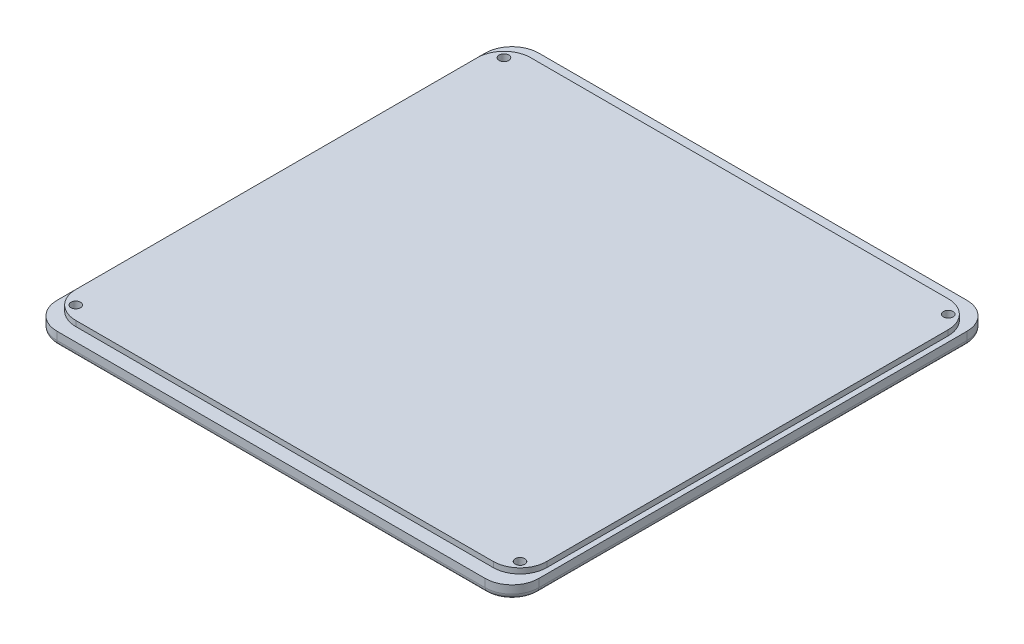
from build123d import *

# Parameters (mm, degrees)
SKIZZE1_W                                            = 180
SKIZZE1_H                                            = 180
AUFSATZ_LINEAR_AUSTRAGEN1_DEPTH                      = 5
AUFSATZ_LINEAR_AUSTRAGEN2_DEPTH                      = 2
STIRNSENKUNG_F_R_M3_ZYLINDERSCHRAUBE_MIT_D           = 3.6
STIRNSENKUNG_F_R_M3_ZYLINDERSCHRAUBE_MIT_DEPTH       = 9.1
STIRNSENKUNG_F_R_M3_ZYLINDERSCHRAUBE_MIT_CBORE_D     = 6.5
STIRNSENKUNG_F_R_M3_ZYLINDERSCHRAUBE_MIT_CBORE_DEPTH = 3.4
STIRNSENKUNG_F_R_M3_ZYLINDERSCHRAUBE_MIT_TIP         = 1.081549114
VERRUNDUNG1_R                                        = 10
VERRUNDUNG2_R                                        = 2


with BuildPart() as part:
    # Skizze1 → Aufsatz-Linear austragen1 (new body)
    with BuildSketch(Plane(origin=(0, 0, 0), x_dir=(1, 0, 0), z_dir=(0, 1, 0))):
        Rectangle(SKIZZE1_W, SKIZZE1_H)
    extrude(amount=AUFSATZ_LINEAR_AUSTRAGEN1_DEPTH)

    # Skizze2 → Aufsatz-Linear austragen2 (add)
    with BuildSketch(Plane(origin=(0, 5, 0), x_dir=(1, 0, 0), z_dir=(0, 1, 0))):
        with BuildLine():
            Line((78, 85), (-78, 85))
            ThreePointArc((-78, 85), (-85.071067812, 82.071067812), (-88, 75))
            Line((-88, 75), (-88, -75))
            ThreePointArc((-88, -75), (-85.071067812, -82.071067812), (-78, -85))
            Line((-78, -85), (78, -85))
            ThreePointArc((78, -85), (85.071067812, -82.071067812), (88, -75))
            Line((88, -75), (88, 75))
            ThreePointArc((88, 75), (85.071067812, 82.071067812), (78, 85))
        make_face()
    extrude(amount=AUFSATZ_LINEAR_AUSTRAGEN2_DEPTH)

    # Stirnsenkung für M3 Zylinderschraube mit Innensechskant2
    with Locations(Plane(origin=(0, 0, 0), x_dir=(-1, 0, 0), z_dir=(0, -1, 0))):
        with Locations((-83, 80), (83, 80), (83, -80), (-83, -80)):
            CounterBoreHole(STIRNSENKUNG_F_R_M3_ZYLINDERSCHRAUBE_MIT_D / 2, STIRNSENKUNG_F_R_M3_ZYLINDERSCHRAUBE_MIT_CBORE_D / 2, STIRNSENKUNG_F_R_M3_ZYLINDERSCHRAUBE_MIT_CBORE_DEPTH, depth=STIRNSENKUNG_F_R_M3_ZYLINDERSCHRAUBE_MIT_DEPTH)
            with Locations((0, 0, -(STIRNSENKUNG_F_R_M3_ZYLINDERSCHRAUBE_MIT_DEPTH + STIRNSENKUNG_F_R_M3_ZYLINDERSCHRAUBE_MIT_TIP / 2))):  # 118° drill point
                Cone(0, STIRNSENKUNG_F_R_M3_ZYLINDERSCHRAUBE_MIT_D / 2, STIRNSENKUNG_F_R_M3_ZYLINDERSCHRAUBE_MIT_TIP, mode=Mode.SUBTRACT)

    # Verrundung1
    verrundung1_edges = [part.edges().sort_by_distance(p)[0] for p in [
        (90, 2.5, -90),
        (90, 2.5, 90),
        (-90, 2.5, 90),
        (-90, 2.5, -90),
    ]]
    fillet(verrundung1_edges, radius=VERRUNDUNG1_R)

    # Verrundung2
    verrundung2_edges = [part.edges().sort_by_distance(p)[0] for p in [
        (90, 0, 0),
        (0, 0, -90),
        (0, 0, 90),
        (-90, 0, 0),
        (87.071067812, 0, -87.071067812),
        (-87.071067812, 0, -87.071067812),
        (-87.071067812, 0, 87.071067812),
        (87.071067812, 0, 87.071067812),
    ]]
    fillet(verrundung2_edges, radius=VERRUNDUNG2_R)


solid = part.part
